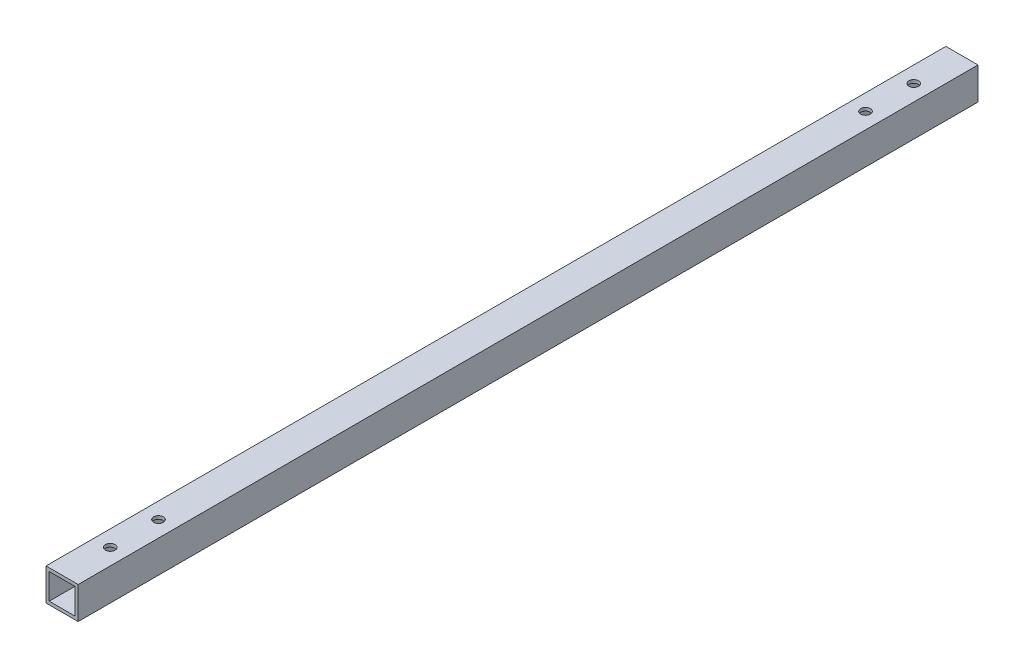
from build123d import *

# Parameters (mm, degrees)
SKETCH2_W           = 10
SKETCH2_H           = 10
SKETCH2_W_2         = 8
SKETCH2_H_2         = 8
BOSS_EXTRUDE1_DEPTH = 280
SKETCH3_R           = 1.5
CUT_EXTRUDE1_DEPTH  = 28


with BuildPart() as part:
    # Sketch2 → Boss-Extrude1 (new body)
    with BuildSketch(Plane.XY):
        Rectangle(SKETCH2_W, SKETCH2_H)
        Rectangle(SKETCH2_W_2, SKETCH2_H_2, mode=Mode.SUBTRACT)
    extrude(amount=BOSS_EXTRUDE1_DEPTH)

    # Sketch3 → Cut-Extrude1 (cut)
    with BuildSketch(Plane(origin=(0, 5, 0), x_dir=(1, 0, 0), z_dir=(0, 1, 0))):
        with Locations((0, -15)):
            Circle(SKETCH3_R)
        with Locations((0, -30)):
            Circle(SKETCH3_R)
        with Locations((0, -265)):
            Circle(SKETCH3_R)
        with Locations((0, -250)):
            Circle(SKETCH3_R)
    extrude(amount=-CUT_EXTRUDE1_DEPTH, mode=Mode.SUBTRACT)


solid = part.part
